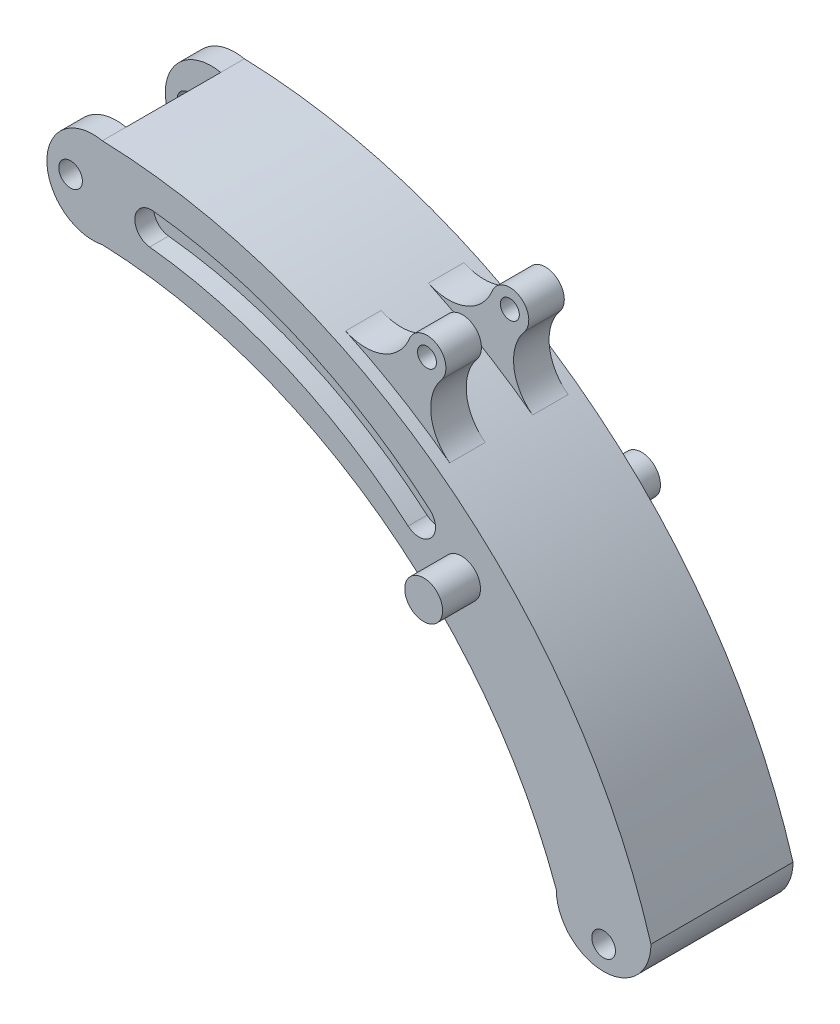
from build123d import *

# Parameters (mm, degrees)
Y_KSEKLIK_EKSTR_ZYON1_DEPTH = 15
Y_KSEKLIK_EKSTR_ZYON2_DEPTH = 5
IZIM4_R                     = 2.5
KES_EKSTR_ZYON1_DEPTH       = 31
Y_KSEKLIK_EKSTR_ZYON3_DEPTH = 12.5
KES_EKSTR_ZYON2_DEPTH       = 5
IZIM7_R                     = 2
KES_EKSTR_ZYON3_DEPTH       = 28.5
IZIM8_R                     = 4
Y_KSEKLIK_EKSTR_ZYON5_DEPTH = 8
KES_EKSTR_ZYON4_DEPTH       = 4
Y_KSEKLIK_EKSTR_ZYON6_DEPTH = 15
IZIM11_R                    = 2.5
KES_EKSTR_ZYON5_DEPTH       = 30


with BuildPart() as part:
    # Çizim1 → Yükseklik-Ekstrüzyon1 (new body, symmetric)
    with BuildSketch(Plane.XY):
        with BuildLine():
            Line((-95.857885087, 89.010731317), (-95.857885087, 70))
            ThreePointArc((-95.857885087, 70), (-37.212348736, 49.675285967), (0, 0))
            Line((0, 0), (20, 0))
            ThreePointArc((20, 0), (-23.570681084, 63.194323514), (-95.857885087, 89.010731317))
        make_face()
    extrude(amount=Y_KSEKLIK_EKSTR_ZYON1_DEPTH, both=True)

    # Çizim3 → Yükseklik-Ekstrüzyon2 (add)
    with BuildSketch(Plane.XY.offset(15)):
        with BuildLine():
            Line((-95.857885087, 89.010731317), (-95.857885087, 70))
            ThreePointArc((-95.857885087, 70), (-107.571379634, 79.505365659), (-95.857885087, 89.010731317))
        make_face()
    y_kseklik_ekstr_zyon2 = extrude(amount=-Y_KSEKLIK_EKSTR_ZYON2_DEPTH)

    # Aynalama1: Yükseklik-Ekstrüzyon2 across plane
    add(y_kseklik_ekstr_zyon2.mirror(Plane.XY))

    # Çizim4 → Kes-Ekstrüzyon1 (cut, through all)
    with BuildSketch(Plane.XY.offset(15)):
        with Locations((-102.571379634, 79.505365659)):
            Circle(IZIM4_R)
    extrude(amount=-KES_EKSTR_ZYON1_DEPTH, mode=Mode.SUBTRACT)

    # Çizim5 → Yükseklik-Ekstrüzyon3 (add, symmetric)
    with BuildSketch(Plane.XY):
        with BuildLine():
            ThreePointArc((-25, 64.276224342), (-35.66270362, 71.406588574), (-47, 77.406676353))
            ThreePointArc((-47, 77.406676353), (-39.114950806, 77.17019229), (-33.511903594, 82.723190348))
            ThreePointArc((-33.511903594, 82.723190348), (-27.753871547, 84.657793137), (-26.723332165, 78.671508013))
            ThreePointArc((-26.723332165, 78.671508013), (-28.951102684, 71.104014108), (-25, 64.276224342))
        make_face()
    extrude(amount=Y_KSEKLIK_EKSTR_ZYON3_DEPTH, both=True)

    # Çizim6 → Kes-Ekstrüzyon2 (cut, symmetric)
    with BuildSketch(Plane.XY):
        with BuildLine():
            ThreePointArc((-25, 64.276224342), (-35.66270362, 71.406588574), (-47, 77.406676353))
            ThreePointArc((-47, 77.406676353), (-39.114950806, 77.17019229), (-33.511903594, 82.723190348))
            ThreePointArc((-33.511903594, 82.723190348), (-27.753871547, 84.657793137), (-26.723332165, 78.671508013))
            ThreePointArc((-26.723332165, 78.671508013), (-28.951102684, 71.104014108), (-25, 64.276224342))
        make_face()
    extrude(amount=KES_EKSTR_ZYON2_DEPTH, both=True, mode=Mode.SUBTRACT)

    # Çizim7 → Kes-Ekstrüzyon3 (cut, through all)
    with BuildSketch(Plane.XY.offset(12.5)):
        with Locations((-29.803865031, 81.223040349)):
            Circle(IZIM7_R)
    extrude(amount=-KES_EKSTR_ZYON3_DEPTH, mode=Mode.SUBTRACT)

    # Çizim8 → Yükseklik-Ekstrüzyon5 (add)
    with BuildSketch(Plane.XY.offset(15)):
        with Locations((-20, 47)):
            Circle(IZIM8_R)
    y_kseklik_ekstr_zyon5 = extrude(amount=Y_KSEKLIK_EKSTR_ZYON5_DEPTH)

    # Aynalama2: Yükseklik-Ekstrüzyon5 across plane
    add(y_kseklik_ekstr_zyon5.mirror(Plane.XY))

    # Çizim9 → Kes-Ekstrüzyon4 (cut)
    with BuildSketch(Plane.XY.offset(15)):
        with BuildLine():
            ThreePointArc((-26.711830739, 56.128041308), (-53.982517061, 73.280029195), (-85.122353286, 81.537850995))
            ThreePointArc((-85.122353286, 81.537850995), (-88.97956649, 78.435931218), (-85.877646714, 74.578718014))
            ThreePointArc((-85.877646714, 74.578718014), (-56.774887256, 66.861098701), (-31.288169261, 50.831143563))
            ThreePointArc((-31.288169261, 50.831143563), (-26.351551127, 51.191423174), (-26.711830739, 56.128041308))
        make_face()
    kes_ekstr_zyon4 = extrude(amount=-KES_EKSTR_ZYON4_DEPTH, mode=Mode.SUBTRACT)

    # Aynalama3: Kes-Ekstrüzyon4 across plane
    add(kes_ekstr_zyon4.mirror(Plane.XY), mode=Mode.SUBTRACT)

    # Çizim10 → Yükseklik-Ekstrüzyon6 (add, symmetric)
    with BuildSketch(Plane.XY):
        with BuildLine():
            Line((0, 0), (20, 0))
            ThreePointArc((20, 0), (10, -10), (0, 0))
        make_face()
    extrude(amount=Y_KSEKLIK_EKSTR_ZYON6_DEPTH, both=True)

    # Çizim11 → Kes-Ekstrüzyon5 (cut)
    with BuildSketch(Plane.XY.offset(15)):
        with Locations((10, -5)):
            Circle(IZIM11_R)
    extrude(amount=-KES_EKSTR_ZYON5_DEPTH, mode=Mode.SUBTRACT)


solid = part.part
